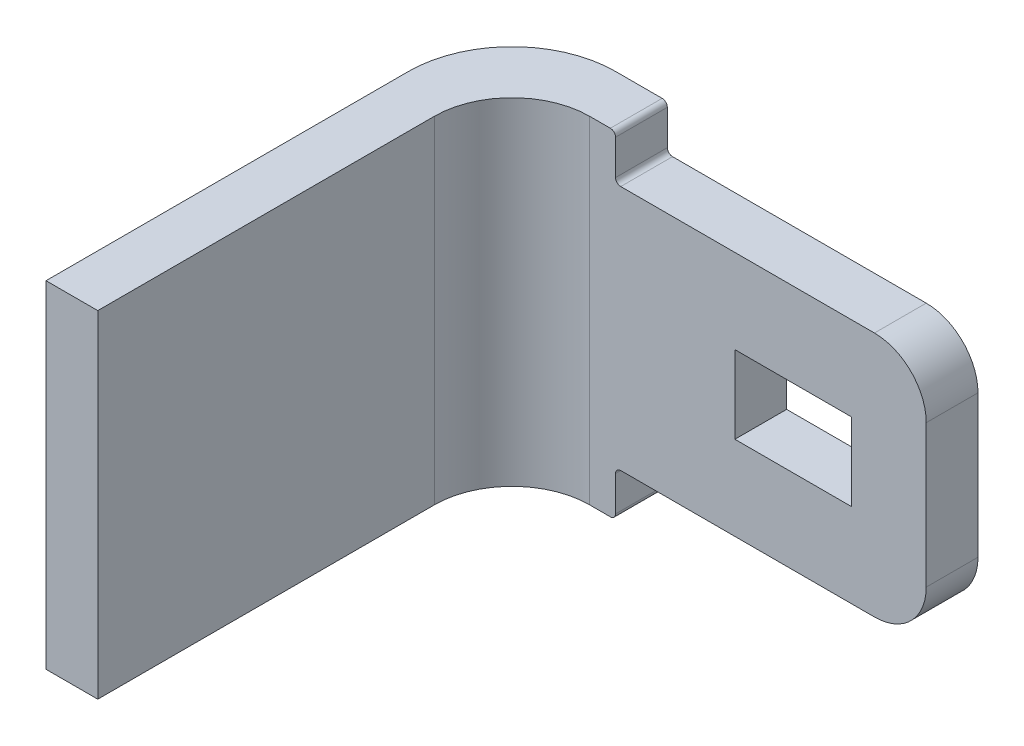
from build123d import *

# Parameters (mm, degrees)
EXTRUDE_1_DEPTH     = 6.5
FILLET_1_R          = 2
FILLET_2_R          = 1.5
SKETCH_2_W          = 6
SKETCH_2_H          = 0.875
CUT_EXTRUDE_1_DEPTH = 10
FILLET_4_R          = 1
FILLET_5_R          = 0.1
FILLET_6_R          = 0.1
SKETCH_3_W          = 2.25
SKETCH_3_H          = 1.5
CUT_EXTRUDE_2_DEPTH = 10


with BuildPart() as part:
    # Эскиз1 → Бобышка-Вытянуть1 (new body)
    with BuildSketch(Plane(origin=(0, 0, 0), x_dir=(1, 0, 0), z_dir=(0, 1, 0))):
        Polygon((-22.702464419, 0), (-21.702464419, 0), (-21.702464419, 8), (-13.702464419, 8), (-13.702464419, 9), (-22.702464419, 9), align=None)
    extrude(amount=EXTRUDE_1_DEPTH)

    # Скругление1
    fillet_1_edges = [part.edges().sort_by_distance(p)[0] for p in [
        (-22.702464419, 3.25, -9),
    ]]
    fillet(fillet_1_edges, radius=FILLET_1_R)

    # Скругление2
    fillet_2_edges = [part.edges().sort_by_distance(p)[0] for p in [
        (-21.702464419, 3.25, -8),
    ]]
    fillet(fillet_2_edges, radius=FILLET_2_R)

    # Эскиз2 → Вырез-Вытянуть1 (cut, through all)
    with BuildSketch(Plane(origin=(0, 0, -9), x_dir=(-1, 0, 0), z_dir=(0, 0, -1))):
        with Locations((16.702464419, 0.4375)):
            Rectangle(SKETCH_2_W, SKETCH_2_H)
        with Locations((16.702464419, 6.0625)):
            Rectangle(SKETCH_2_W, SKETCH_2_H)
    extrude(amount=-CUT_EXTRUDE_1_DEPTH, mode=Mode.SUBTRACT)

    # Скругление4
    fillet_4_edges = [part.edges().sort_by_distance(p)[0] for p in [
        (-13.702464419, 0.875, -8.5),
        (-13.702464419, 5.625, -8.5),
    ]]
    fillet(fillet_4_edges, radius=FILLET_4_R)

    # Скругление5
    fillet_5_edges = [part.edges().sort_by_distance(p)[0] for p in [
        (-19.702464419, 0, -8.5),
        (-19.702464419, 6.5, -8.5),
    ]]
    fillet(fillet_5_edges, radius=FILLET_5_R)

    # Скругление6
    fillet_6_edges = [part.edges().sort_by_distance(p)[0] for p in [
        (-19.702464419, 0.875, -8.5),
        (-19.702464419, 5.625, -8.5),
    ]]
    fillet(fillet_6_edges, radius=FILLET_6_R)

    # Эскиз3 → Вырез-Вытянуть2 (cut, through all)
    with BuildSketch(Plane(origin=(0, 0, -9), x_dir=(-1, 0, 0), z_dir=(0, 0, -1))):
        with Locations((16.273003047, 3.25)):
            Rectangle(SKETCH_3_W, SKETCH_3_H)
    extrude(amount=-CUT_EXTRUDE_2_DEPTH, mode=Mode.SUBTRACT)


solid = part.part
